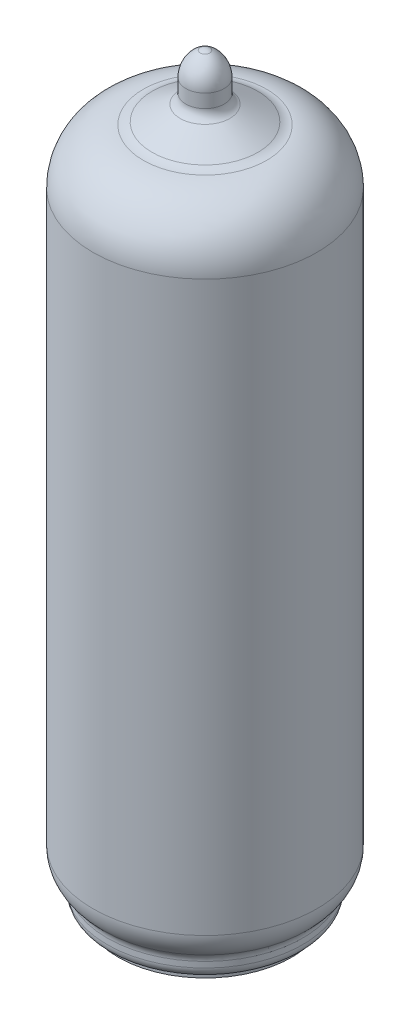
from build123d import *

# Parameters (mm, degrees)
FILLET1_R         = 1
FILLET2_R         = 1
CIRPATTERN1_COUNT = 9
CIRPATTERN1_ANGLE = 288


with BuildPart() as part:
    # Sketch1 → Revolve-Thin1 (revolve)
    with BuildSketch(Plane.XY):
        with BuildLine():
            ThreePointArc((8.940885241, 2.5), (9.902918783, 3.588991367), (10.25, 5))
            Line((10.25, 5), (10.25, 57))
            ThreePointArc((10.25, 57), (8.921513286, 60.394111105), (5.642003923, 61.984609606))
            ThreePointArc((5.642003923, 61.984609606), (5.229658561, 62.061144978), (4.842339495, 62.221987452))
            Line((4.842339495, 62.221987452), (2.271767002, 63.621767002))
            ThreePointArc((2.271767002, 63.621767002), (1.890281151, 63.98923244), (1.75, 64.5))
            Line((1.75, 64.5), (0.95, 64.5))
            ThreePointArc((0.95, 64.5), (1.202506072, 63.580618391), (1.889180603, 62.919180603))
            Line((1.889180603, 62.919180603), (4.459753097, 61.519401053))
            ThreePointArc((4.459753097, 61.519401053), (5.001999789, 61.29422159), (5.579283295, 61.187072069))
            ThreePointArc((5.579283295, 61.187072069), (8.33407116, 59.851053328), (9.45, 57))
            Line((9.45, 57), (9.45, 5))
            ThreePointArc((9.45, 5), (9.194205898, 3.960105966), (8.485200355, 3.157534247))
            Line((8.485200355, 3.157534247), (8.940885241, 2.5))
        make_face()
    revolve(axis=Axis((0, 93.537011177, 0), (0, -1, 0)))

    # Sketch2 → Revolve1 (revolve)
    with BuildSketch(Plane.XY):
        with BuildLine():
            Line((1.75, 64.5), (0.95, 64.5))
            Line((0.95, 64.5), (0.95, 64.75))
            ThreePointArc((0.95, 64.75), (0.671751442, 65.421751442), (0, 65.7))
            Line((0, 65.7), (0, 68))
            ThreePointArc((0, 68), (0.225854237, 67.972755613), (0.438751251, 67.892585457))
            ThreePointArc((0.438751251, 67.892585457), (1.396558109, 66.9951952), (1.75, 65.73116115))
            Line((1.75, 65.73116115), (1.75, 64.5))
        make_face()
    revolve(axis=Axis((0, 69.232678815, 0), (0, -1, 0)))

    # Sketch3 → Revolve2 (revolve)
    with BuildSketch(Plane.XY):
        with BuildLine():
            Line((-8.940885241, 2.5), (-8.485200355, 3.157534247))
            Line((-8.485200355, 3.157534247), (0, 3.157534247))
            Line((0, 3.157534247), (0, 0))
            Line((0, 0), (-7.940885241, 0))
            Line((-7.940885241, 0), (-7.940885241, 0.275255129))
            ThreePointArc((-7.940885241, 0.275255129), (-7.997236073, 0.433369012), (-8.140885241, 0.520204103))
            ThreePointArc((-8.140885241, 0.520204103), (-8.71548191, 0.867544468), (-8.940885241, 1.5))
            Line((-8.940885241, 1.5), (-8.940885241, 2.5))
        make_face()
    revolve(axis=Axis((0, 10.794798164, 0), (0, -1, 0)))

    # Fillet1
    fillet1_edges = [part.edges().sort_by_distance(p)[0] for p in [
        (0, 2.5, 8.940885241),
    ]]
    fillet(fillet1_edges, radius=FILLET1_R)

    # Fillet2
    fillet2_edges = [part.edges().sort_by_distance(p)[0] for p in [
        (-8.485200355, 3.157534247, 0),
    ]]
    fillet(fillet2_edges, radius=FILLET2_R)

    # Sketch4 → Revolve3 (revolve)
    with BuildSketch(Plane(origin=(0, 0, 0), x_dir=(0.587785252, 0, -0.809016994), z_dir=(0.809016994, 0, 0.587785252))):
        with BuildLine():
            Line((-6.533053794, 5), (-6, 5))
            Line((-6, 5), (-6, 0))
            Line((-6, 0), (-7.4, 0))
            Line((-7.4, 0), (-7.4, 3.256821844))
            ThreePointArc((-7.4, 3.256821844), (-7.371013122, 3.550284609), (-7.285172808, 3.832405281))
            Line((-7.285172808, 3.832405281), (-6.90243321, 4.753488916))
            ThreePointArc((-6.90243321, 4.753488916), (-6.755094819, 4.932712764), (-6.533053794, 5))
        make_face()
    revolve3 = revolve(axis=Axis((-3.526711514, 12.504674085, 4.854101966), (0, -1, 0)))

    # CirPattern1: Revolve3 ×9 about axis
    cirpattern1_axis = Axis((0, 0, 0), (0, -1, 0))
    for i in range(1, CIRPATTERN1_COUNT):
        add(revolve3.rotate(cirpattern1_axis, i * CIRPATTERN1_ANGLE / (CIRPATTERN1_COUNT - 1)))


solid = part.part
